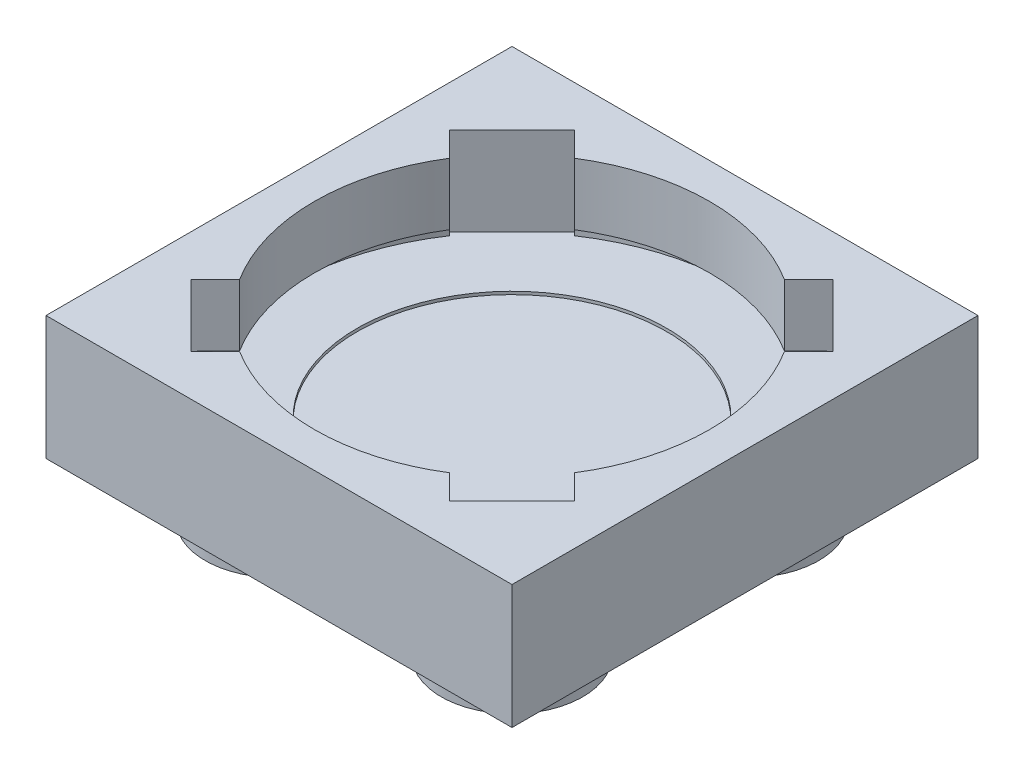
from build123d import *

# Parameters (mm, degrees)
SKETCH2_W            = 15.8
SKETCH2_H            = 15.8
BOSS_EXTRUDE2_DEPTH  = 4.2
SKETCH4_W            = 13.4
SKETCH4_H            = 13.4
CUT_EXTRUDE1_DEPTH   = 3
SKETCH6_R            = 2.4
BOSS_EXTRUDE4_DEPTH  = 1.8
LPATTERN1_COUNT      = 2
LPATTERN1_PITCH      = 8
LPATTERN1_COUNT_DIR2 = 2
LPATTERN1_PITCH_DIR2 = 8
SKETCH8_R            = 5.25
CUT_EXTRUDE2_DEPTH   = 0.1
BOSS_EXTRUDE9_DEPTH  = 3
CUT_EXTRUDE3_DEPTH   = 3
CIRPATTERN3_COUNT    = 4
SKETCH19_W           = 1.484523383
SKETCH19_H           = 0.9


with BuildPart() as part:
    # Sketch2 → Boss-Extrude2 (new body)
    with BuildSketch(Plane(origin=(0, 0, 0), x_dir=(1, 0, 0), z_dir=(0, 1, 0))):
        with Locations((7.9, 7.9)):
            Rectangle(SKETCH2_W, SKETCH2_H)
    extrude(amount=-BOSS_EXTRUDE2_DEPTH)

    # Sketch4 → Cut-Extrude1 (cut)
    with BuildSketch(Plane(origin=(0, 0, 0), x_dir=(1, 0, 0), z_dir=(0, 1, 0))):
        with Locations((7.9, 7.9)):
            Rectangle(SKETCH4_W, SKETCH4_H)
    extrude(amount=-CUT_EXTRUDE1_DEPTH, mode=Mode.SUBTRACT)

    # Sketch6 → Boss-Extrude4 (add)
    with BuildSketch(Plane(origin=(0, -4.2, 0), x_dir=(-1, 0, 0), z_dir=(0, -1, 0))):
        with Locations((-11.9, 11.9)):
            Circle(SKETCH6_R)
    boss_extrude4 = extrude(amount=BOSS_EXTRUDE4_DEPTH)

    # LPattern1: Boss-Extrude4 2 × 2
    with Locations(*[(-j * LPATTERN1_PITCH_DIR2, 0, i * LPATTERN1_PITCH) for i in range(LPATTERN1_COUNT) for j in range(LPATTERN1_COUNT_DIR2) if (i, j) != (0, 0)]):
        add(boss_extrude4)

    # Sketch8 → Cut-Extrude2 (cut)
    with BuildSketch(Plane(origin=(0, -3, 0), x_dir=(1, 0, 0), z_dir=(0, 1, 0))):
        with Locations((7.9, 7.9)):
            Circle(SKETCH8_R)
    extrude(amount=-CUT_EXTRUDE2_DEPTH, mode=Mode.SUBTRACT)

    # Sketch11 → Boss-Extrude9 (add)
    with BuildSketch(Plane(origin=(0, -3, 0), x_dir=(1, 0, 0), z_dir=(0, 1, 0))):
        with BuildLine():
            Line((7.899999971, 14.6), (1.2, 14.6))
            Line((1.2, 14.6), (1.2, 7.9))
            ThreePointArc((1.2, 7.9), (3.162384556, 12.637615424), (7.899999971, 14.6))
        make_face()
        with BuildLine():
            Line((14.6, 14.6), (7.899999971, 14.6))
            ThreePointArc((7.899999971, 14.6), (12.637615424, 12.637615444), (14.6, 7.9))
            Line((14.6, 7.9), (14.6, 14.6))
        make_face()
        with BuildLine():
            ThreePointArc((7.900000011, 1.2), (3.16238457, 3.162384562), (1.2, 7.9))
            Line((1.2, 7.9), (1.2, 1.2))
            Line((1.2, 1.2), (7.900000011, 1.2))
        make_face()
        with BuildLine():
            Line((14.6, 1.2), (14.6, 7.9))
            ThreePointArc((14.6, 7.9), (12.637615438, 3.16238457), (7.900000011, 1.2))
            Line((7.900000011, 1.2), (14.6, 1.2))
        make_face()
    extrude(amount=BOSS_EXTRUDE9_DEPTH)

    # Sketch12 → Cut-Extrude3 (cut)
    with BuildSketch(Plane(origin=(0, 0, 0), x_dir=(1, 0, 0), z_dir=(0, 1, 0))):
        Polygon((3.162384566, 12.637615434), (2.455277785, 13.344722215), (1.394617613, 12.284062043), (2.101724394, 11.576955262), align=None)
        with BuildLine():
            ThreePointArc((2.221981276, 11.45669838), (2.658816927, 12.073727351), (3.162384566, 12.637615434))
            Line((3.162384566, 12.637615434), (2.101724394, 11.576955262))
            Line((2.101724394, 11.576955262), (2.221981276, 11.45669838))
        make_face()
        with BuildLine():
            Line((4.223044738, 13.698275606), (3.162384566, 12.637615434))
            ThreePointArc((3.162384566, 12.637615434), (3.726272649, 13.141183073), (4.34330162, 13.578018724))
            Line((4.34330162, 13.578018724), (4.223044738, 13.698275606))
        make_face()
        Polygon((3.515937957, 14.405382387), (2.455277785, 13.344722215), (3.162384566, 12.637615434), (4.223044738, 13.698275606), align=None)
        with BuildLine():
            ThreePointArc((4.34330162, 13.578018724), (3.726272649, 13.141183073), (3.162384566, 12.637615434))
            ThreePointArc((3.162384566, 12.637615434), (2.658816927, 12.073727351), (2.221981276, 11.45669838))
            Line((2.221981276, 11.45669838), (2.423581348, 11.255098309))
            Line((2.423581348, 11.255098309), (4.544901691, 13.376418652))
            Line((4.544901691, 13.376418652), (4.34330162, 13.578018724))
        make_face()
        with BuildLine():
            ThreePointArc((14.6, 7.9), (11.145005458, 13.761735202), (4.34330162, 13.578018724))
            Line((4.34330162, 13.578018724), (4.544901691, 13.376418652))
            Line((4.544901691, 13.376418652), (2.423581348, 11.255098309))
            Line((2.423581348, 11.255098309), (2.221981276, 11.45669838))
            ThreePointArc((2.221981276, 11.45669838), (6.049692654, 1.460561925), (14.6, 7.9))
        make_face()
    cut_extrude3 = extrude(amount=-CUT_EXTRUDE3_DEPTH, mode=Mode.SUBTRACT)

    # CirPattern3: Cut-Extrude3 ×4 about axis
    cirpattern3_axis = Axis((7.9, 0, -7.9), (0, 1, 0))
    for i in range(1, CIRPATTERN3_COUNT):
        add(cut_extrude3.rotate(cirpattern3_axis, i * 360 / CIRPATTERN3_COUNT), mode=Mode.SUBTRACT)

    # Sketch19 → Cut-Revolve1 (revolve, cut)
    with BuildSketch(Plane(origin=(7.9, 0, -7.9), x_dir=(0.707106781, 0, 0.707106781), z_dir=(-0.707106781, 0, 0.707106781))):
        with Locations((-6.957738308, -2.55)):
            Rectangle(SKETCH19_W, SKETCH19_H)
    revolve(axis=Axis((7.9, 0, -7.9), (0, -1, 0)), mode=Mode.SUBTRACT)


solid = part.part
